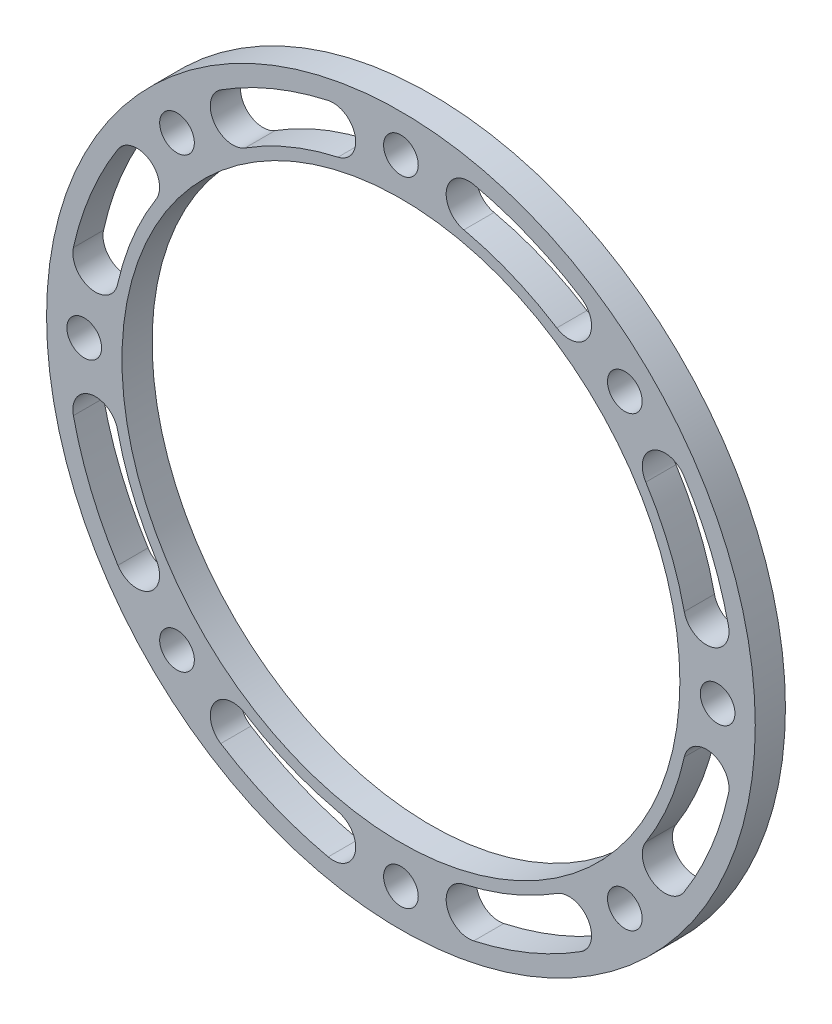
from build123d import *

# Parameters (mm, degrees)
SKETCH_1_R          = 47
SKETCH_1_R_2        = 37
SKETCH_1_R_3        = 2.3
EXTRUDE_1_DEPTH     = 4
CUT_EXTRUDE_1_DEPTH = 5


with BuildPart() as part:
    # 草图1 → 凸台-拉伸1 (new body)
    with BuildSketch(Plane.XY):
        Circle(SKETCH_1_R)
        Circle(SKETCH_1_R_2, mode=Mode.SUBTRACT)
        with Locations((0, 42)):
            Circle(SKETCH_1_R_3, mode=Mode.SUBTRACT)
        with Locations((29.69848481, 29.69848481)):
            Circle(SKETCH_1_R_3, mode=Mode.SUBTRACT)
        with Locations((42, 0)):
            Circle(SKETCH_1_R_3, mode=Mode.SUBTRACT)
        with Locations((29.69848481, -29.69848481)):
            Circle(SKETCH_1_R_3, mode=Mode.SUBTRACT)
        with Locations((0, -42)):
            Circle(SKETCH_1_R_3, mode=Mode.SUBTRACT)
        with Locations((-29.69848481, -29.69848481)):
            Circle(SKETCH_1_R_3, mode=Mode.SUBTRACT)
        with Locations((-42, 0)):
            Circle(SKETCH_1_R_3, mode=Mode.SUBTRACT)
        with Locations((-29.69848481, 29.69848481)):
            Circle(SKETCH_1_R_3, mode=Mode.SUBTRACT)
    extrude(amount=EXTRUDE_1_DEPTH)

    # 草图3 → 切除-拉伸1 (cut, through all)
    with BuildSketch(Plane.XY.offset(4)):
        with BuildLine():
            ThreePointArc((23.893381773, 37.541394586), (17.02941274, 41.112639197), (9.65060241, 43.440946964))
            ThreePointArc((9.65060241, 43.440946964), (6.071396834, 41.162946208), (8.34939759, 37.583740632))
            ThreePointArc((8.34939759, 37.583740632), (14.733312146, 35.569362002), (20.671802208, 32.479633518))
            ThreePointArc((20.671802208, 32.479633518), (24.813472524, 33.399724269), (23.893381773, 37.541394586))
        make_face()
        with BuildLine():
            ThreePointArc((43.440946964, 9.65060241), (41.112639197, 17.02941274), (37.541394586, 23.893381773))
            ThreePointArc((37.541394586, 23.893381773), (33.399724269, 24.813472524), (32.479633518, 20.671802208))
            ThreePointArc((32.479633518, 20.671802208), (35.569362002, 14.733312146), (37.583740632, 8.34939759))
            ThreePointArc((37.583740632, 8.34939759), (41.162946208, 6.071396834), (43.440946964, 9.65060241))
        make_face()
        with BuildLine():
            ThreePointArc((37.541394586, -23.893381773), (41.112639197, -17.02941274), (43.440946964, -9.65060241))
            ThreePointArc((43.440946964, -9.65060241), (41.162946208, -6.071396834), (37.583740632, -8.34939759))
            ThreePointArc((37.583740632, -8.34939759), (35.569362002, -14.733312146), (32.479633518, -20.671802208))
            ThreePointArc((32.479633518, -20.671802208), (33.399724269, -24.813472524), (37.541394586, -23.893381773))
        make_face()
        with BuildLine():
            ThreePointArc((9.65060241, -43.440946964), (17.02941274, -41.112639197), (23.893381773, -37.541394586))
            ThreePointArc((23.893381773, -37.541394586), (24.813472524, -33.399724269), (20.671802208, -32.479633518))
            ThreePointArc((20.671802208, -32.479633518), (14.733312146, -35.569362002), (8.34939759, -37.583740632))
            ThreePointArc((8.34939759, -37.583740632), (6.071396834, -41.162946208), (9.65060241, -43.440946964))
        make_face()
        with BuildLine():
            ThreePointArc((-23.893381773, -37.541394586), (-17.02941274, -41.112639197), (-9.65060241, -43.440946964))
            ThreePointArc((-9.65060241, -43.440946964), (-6.071396834, -41.162946208), (-8.34939759, -37.583740632))
            ThreePointArc((-8.34939759, -37.583740632), (-14.733312146, -35.569362002), (-20.671802208, -32.479633518))
            ThreePointArc((-20.671802208, -32.479633518), (-24.813472524, -33.399724269), (-23.893381773, -37.541394586))
        make_face()
        with BuildLine():
            ThreePointArc((-43.440946964, -9.65060241), (-41.112639197, -17.02941274), (-37.541394586, -23.893381773))
            ThreePointArc((-37.541394586, -23.893381773), (-33.399724269, -24.813472524), (-32.479633518, -20.671802208))
            ThreePointArc((-32.479633518, -20.671802208), (-35.569362002, -14.733312146), (-37.583740632, -8.34939759))
            ThreePointArc((-37.583740632, -8.34939759), (-41.162946208, -6.071396834), (-43.440946964, -9.65060241))
        make_face()
        with BuildLine():
            ThreePointArc((-37.541394586, 23.893381773), (-41.112639197, 17.02941274), (-43.440946964, 9.65060241))
            ThreePointArc((-43.440946964, 9.65060241), (-41.162946208, 6.071396834), (-37.583740632, 8.34939759))
            ThreePointArc((-37.583740632, 8.34939759), (-35.569362002, 14.733312146), (-32.479633518, 20.671802208))
            ThreePointArc((-32.479633518, 20.671802208), (-33.399724269, 24.813472524), (-37.541394586, 23.893381773))
        make_face()
        with BuildLine():
            ThreePointArc((-9.65060241, 43.440946964), (-17.02941274, 41.112639197), (-23.893381773, 37.541394586))
            ThreePointArc((-23.893381773, 37.541394586), (-24.813472524, 33.399724269), (-20.671802208, 32.479633518))
            ThreePointArc((-20.671802208, 32.479633518), (-14.733312146, 35.569362002), (-8.34939759, 37.583740632))
            ThreePointArc((-8.34939759, 37.583740632), (-6.071396834, 41.162946208), (-9.65060241, 43.440946964))
        make_face()
    extrude(amount=-CUT_EXTRUDE_1_DEPTH, mode=Mode.SUBTRACT)


with BuildPart() as part_1:
    # Move Body 1: moved
    add(part.part.moved(Location((0, 0, -4))))


solid = part_1.part
